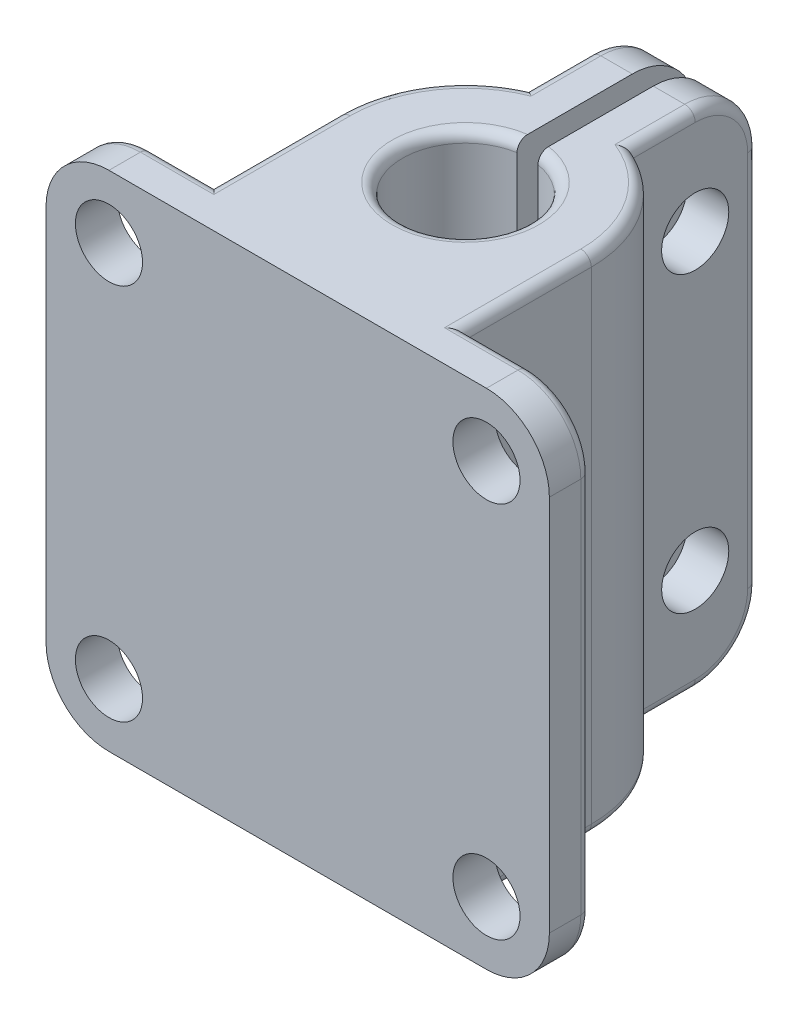
from build123d import *

# Parameters (mm, degrees)
BOSS_EXTRUDE1_DEPTH = 24
SKETCH2_R           = 1.6
CUT_EXTRUDE1_DEPTH  = 9.5
SKETCH3_W           = 24
SKETCH3_H           = 24
BOSS_EXTRUDE2_DEPTH = 2
SKETCH4_R           = 1.6
CUT_EXTRUDE2_DEPTH  = 3
FILLET3_R           = 3
FILLET4_R           = 3
FILLET5_R           = 0.5
FILLET6_R           = 0.5


with BuildPart() as part:
    # Sketch1 → Boss-Extrude1 (new body)
    with BuildSketch(Plane(origin=(0, 0, 0), x_dir=(1, 0, 0), z_dir=(0, 1, 0))):
        with BuildLine():
            Line((-6, 6), (-6, 0))
            Line((-6, 0), (6, 0))
            Line((6, 0), (6, 6))
            ThreePointArc((6, 6), (5.049752469, 9.240370349), (2.5, 11.454356057))
            Line((2.5, 11.454356057), (2.5, 17.454356057))
            Line((2.5, 17.454356057), (0.5, 17.454356057))
            Line((0.5, 17.454356057), (0.5, 8.958039892))
            ThreePointArc((0.5, 8.958039892), (0, 3), (-0.5, 8.958039892))
            Line((-0.5, 8.958039892), (-0.5, 17.454356057))
            Line((-0.5, 17.454356057), (-2.5, 17.454356057))
            Line((-2.5, 17.454356057), (-2.5, 11.454356057))
            ThreePointArc((-2.5, 11.454356057), (-5.049752469, 9.240370349), (-6, 6))
        make_face()
    extrude(amount=BOSS_EXTRUDE1_DEPTH)

    # Sketch2 → Cut-Extrude1 (cut, through all)
    with BuildSketch(Plane(origin=(2.5, 0, 0), x_dir=(0, 0, -1), z_dir=(1, 0, 0))):
        with Locations((14.454356057, 19)):
            Circle(SKETCH2_R)
        with Locations((14.454356057, 5)):
            Circle(SKETCH2_R)
    extrude(amount=-CUT_EXTRUDE1_DEPTH, mode=Mode.SUBTRACT)

    # Sketch3 → Boss-Extrude2 (add)
    with BuildSketch(Plane.XY):
        with Locations((0, 12)):
            Rectangle(SKETCH3_W, SKETCH3_H)
    extrude(amount=BOSS_EXTRUDE2_DEPTH)

    # Sketch4 → Cut-Extrude2 (cut)
    with BuildSketch(Plane(origin=(0, 0, 0), x_dir=(-1, 0, 0), z_dir=(0, 0, -1))):
        with Locations((9, 3)):
            Circle(SKETCH4_R)
        with Locations((9, 21)):
            Circle(SKETCH4_R)
        with Locations((-9, 21)):
            Circle(SKETCH4_R)
        with Locations((-9, 3)):
            Circle(SKETCH4_R)
    extrude(amount=-CUT_EXTRUDE2_DEPTH, mode=Mode.SUBTRACT)

    # Fillet3
    fillet3_edges = [part.edges().sort_by_distance(p)[0] for p in [
        (12, 0, 1),
        (12, 24, 1),
        (-12, 24, 1),
        (-12, 0, 1),
    ]]
    fillet(fillet3_edges, radius=FILLET3_R)

    # Fillet4
    fillet4_edges = [part.edges().sort_by_distance(p)[0] for p in [
        (-1.5, 0, -17.454356057),
        (1.5, 0, -17.454356057),
        (1.5, 24, -17.454356057),
        (-1.5, 24, -17.454356057),
    ]]
    fillet(fillet4_edges, radius=FILLET4_R)

    # Fillet5
    fillet5_edges = [part.edges().sort_by_distance(p)[0] for p in [
        (0, 0, -3),
        (0, 24, -3),
    ]]
    fillet(fillet5_edges, radius=FILLET5_R)

    # Fillet6
    fillet6_edges = [part.edges().sort_by_distance(p)[0] for p in [
        (2.5, 12, -17.454356057),
        (-2.5, 0, -12.954356057),
        (2.5, 23.121320344, -16.575676401),
        (2.5, 0.878679656, -16.575676401),
        (-2.5, 24, -12.954356057),
        (-2.5, 12, -17.454356057),
        (-2.5, 23.121320344, -16.575676401),
        (-2.5, 0.878679656, -16.575676401),
        (6, 24, -3),
        (2.5, 0, -12.954356057),
        (5.049752469, 0, -9.240370349),
        (6, 0, -3),
        (-6, 0, -3),
        (-5.049752469, 0, -9.240370349),
        (5.049752469, 24, -9.240370349),
        (2.5, 24, -12.954356057),
        (-5.049752469, 24, -9.240370349),
        (-7.5, 24, 0),
        (7.5, 0, 0),
        (-6, 24, -3),
        (-7.5, 0, 0),
        (-12, 12, 0),
        (-11.121320344, 23.121320344, 0),
        (-11.121320344, 0.878679656, 0),
        (12, 12, 0),
        (7.5, 24, 0),
        (11.121320344, 23.121320344, 0),
        (11.121320344, 0.878679656, 0),
    ]]
    fillet(fillet6_edges, radius=FILLET6_R)


solid = part.part
